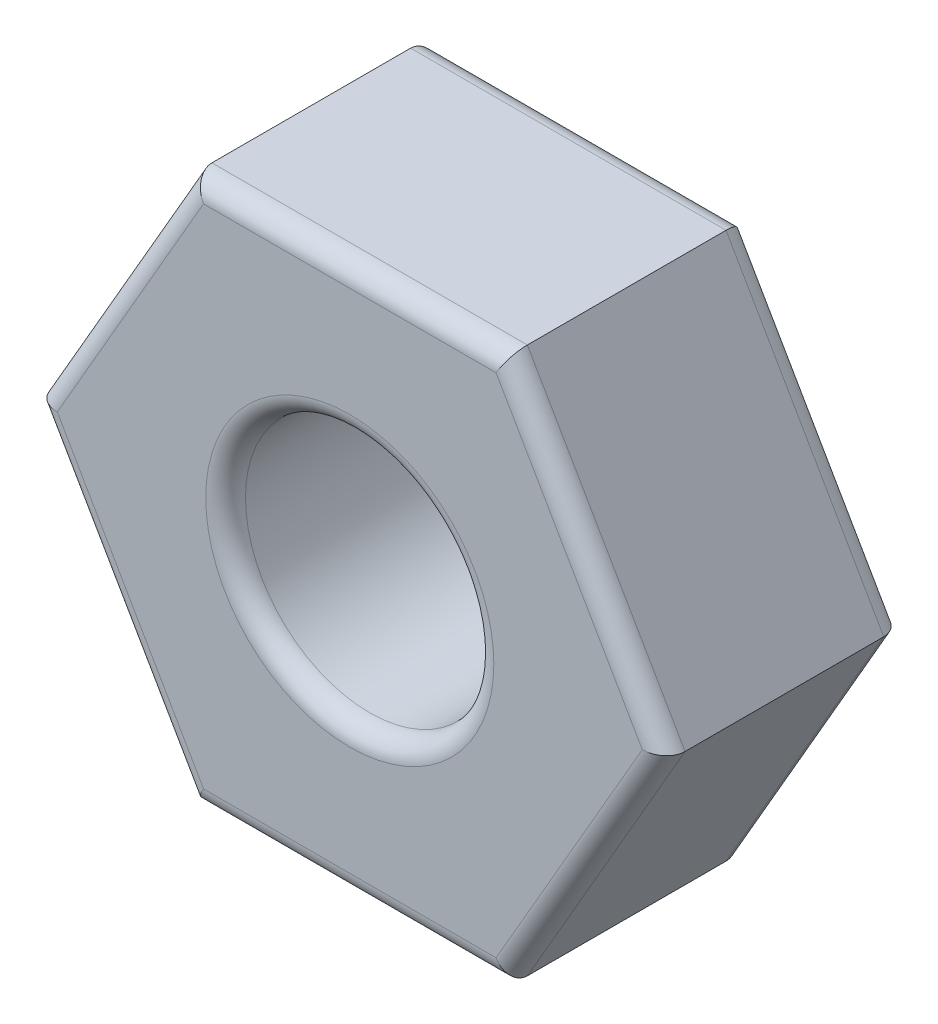
from build123d import *

# Parameters (mm, degrees)
SKETCH1_R           = 1.25
BOSS_EXTRUDE1_DEPTH = 2.4
FILLET1_R           = 0.2


with BuildPart() as part:
    # Sketch1 → Boss-Extrude1 (new body)
    with BuildSketch(Plane.XY):
        Polygon((3.175426481, 0), (1.58771324, 2.75), (-1.58771324, 2.75), (-3.175426481, 0), (-1.58771324, -2.75), (1.58771324, -2.75), align=None)
        Circle(SKETCH1_R, mode=Mode.SUBTRACT)
    extrude(amount=BOSS_EXTRUDE1_DEPTH)

    # Fillet1
    fillet1_edges = [part.edges().sort_by_distance(p)[0] for p in [
        (0, 2.75, 2.4),
        (-2.38156986, 1.375, 2.4),
        (-2.38156986, -1.375, 2.4),
        (-1.25, 0, 0),
        (-1.25, 0, 2.4),
        (0, -2.75, 2.4),
        (2.38156986, -1.375, 2.4),
        (0, -2.75, 0),
        (-2.38156986, -1.375, 0),
        (-2.38156986, 1.375, 0),
        (2.38156986, 1.375, 2.4),
        (0, 2.75, 0),
        (2.38156986, 1.375, 0),
        (2.38156986, -1.375, 0),
    ]]
    fillet(fillet1_edges, radius=FILLET1_R)


solid = part.part
